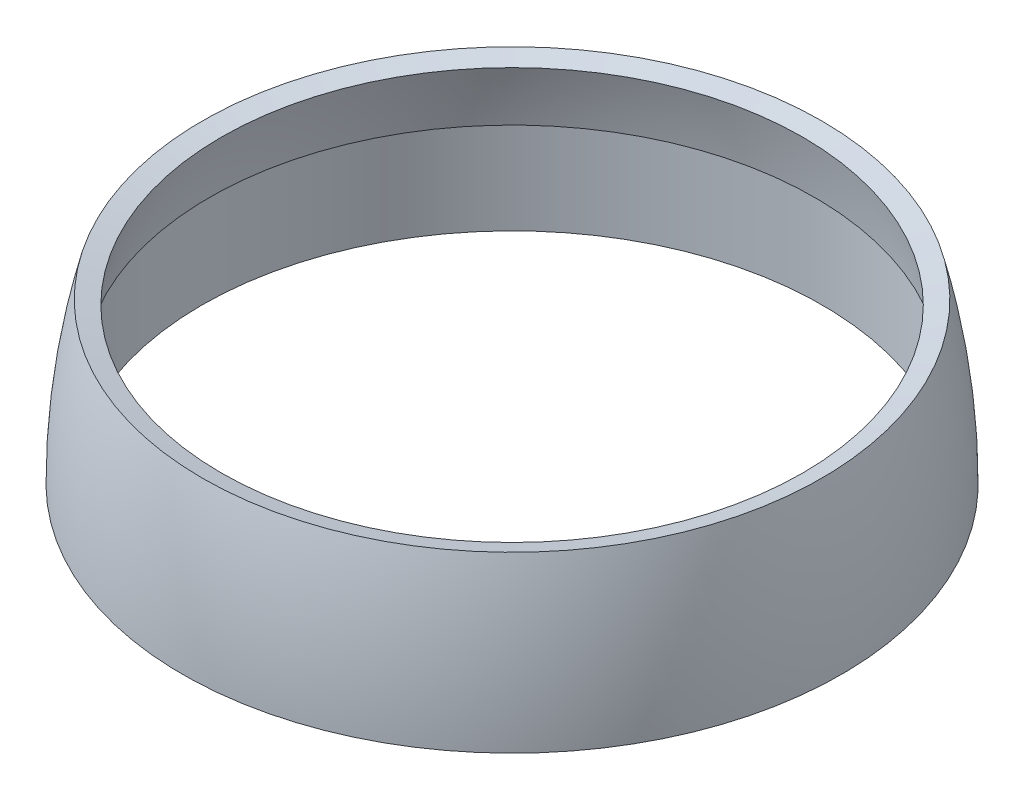
from build123d import *

# Parameters (mm, degrees)
SKETCH3_W = 16
SKETCH3_H = 5


with BuildPart() as part:
    # Sketch2 → Revolve-Thin1 (revolve)
    with BuildSketch(Plane.XY):
        with BuildLine():
            ThreePointArc((15, 8), (15.749030993, 4.031128874), (16, 0))
            Line((16, 0), (17, 0))
            ThreePointArc((17, 0), (16.74130887, 4.155163609), (15.969230769, 8.246153846))
            Line((15.969230769, 8.246153846), (15, 8))
        make_face()
    revolve(axis=Axis((0, 0, 0), (0, 1, 0)))

    # Sketch3 → Cut-Revolve1 (revolve, cut)
    with BuildSketch(Plane.XY):
        with Locations((8, 2.5)):
            Rectangle(SKETCH3_W, SKETCH3_H)
    revolve(axis=Axis((0, 5, 0), (0, -1, 0)), mode=Mode.SUBTRACT)


solid = part.part
